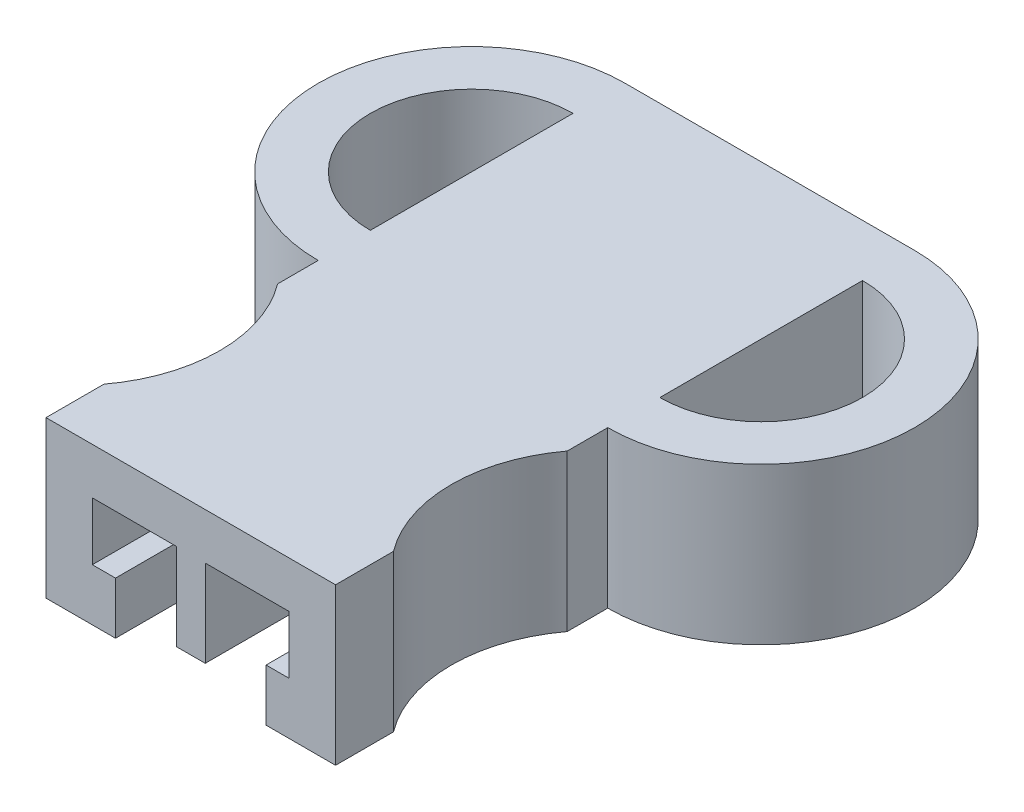
from build123d import *

# Parameters (mm, degrees)
BOSS_EXTRUDE1_DEPTH = 6.858
CUT_EXTRUDE1_DEPTH  = 26.4
BOSS_EXTRUDE2_DEPTH = 6.858
SKETCH6_W           = 1.27
SKETCH6_H           = 3.81
CUT_EXTRUDE2_DEPTH  = 6.35


with BuildPart() as part:
    # Sketch1 → Boss-Extrude1 (new body)
    with BuildSketch(Plane(origin=(0, 0, 0), x_dir=(1, 0, 0), z_dir=(0, 1, 0))):
        with BuildLine():
            Line((0, -22.86), (0, -25.4))
            Line((0, -25.4), (12.7, -25.4))
            Line((12.7, -25.4), (12.7, -22.86))
            ThreePointArc((12.7, -22.86), (11.43, -19.05), (12.7, -15.24))
            Line((12.7, -15.24), (12.7, 0))
            Line((12.7, 0), (0, 0))
            Line((0, 0), (0, -15.24))
            ThreePointArc((0, -15.24), (1.27, -19.05), (0, -22.86))
        make_face()
    extrude(amount=BOSS_EXTRUDE1_DEPTH)

    # Sketch2 → Cut-Extrude1 (cut, through all)
    with BuildSketch(Plane.XY.offset(25.4)):
        Polygon((3.048, 0), (3.048, 2.286), (2.032, 2.286), (2.032, 4.826), (5.715, 4.826), (5.715, 1.016), (6.985, 1.016), (6.985, 4.826), (10.668, 4.826), (10.668, 2.286), (9.652, 2.286), (9.652, 0), align=None)
    extrude(amount=-CUT_EXTRUDE1_DEPTH, mode=Mode.SUBTRACT)

    # Sketch5 → Boss-Extrude2 (add, through all)
    with BuildSketch(Plane(origin=(0, 6.858, 0), x_dir=(1, 0, 0), z_dir=(0, 1, 0))):
        with BuildLine():
            Line((0, 0), (0, -2.286))
            ThreePointArc((0, -2.286), (-4.445, -6.731), (0, -11.176))
            Line((0, -11.176), (0, -13.462))
            ThreePointArc((0, -13.462), (-6.731, -6.731), (0, 0))
        make_face()
        with BuildLine():
            Line((12.7, -13.462), (12.7, -11.176))
            ThreePointArc((12.7, -11.176), (17.145, -6.731), (12.7, -2.286))
            Line((12.7, -2.286), (12.7, 0))
            ThreePointArc((12.7, 0), (19.431, -6.731), (12.7, -13.462))
        make_face()
    extrude(amount=-BOSS_EXTRUDE2_DEPTH)

    # Sketch6 → Cut-Extrude2 (cut)
    with BuildSketch(Plane(origin=(0, 0, 0), x_dir=(-1, 0, 0), z_dir=(0, 0, -1))):
        with Locations((-6.35, 2.921)):
            Rectangle(SKETCH6_W, SKETCH6_H)
    extrude(amount=-CUT_EXTRUDE2_DEPTH, mode=Mode.SUBTRACT)


solid = part.part
